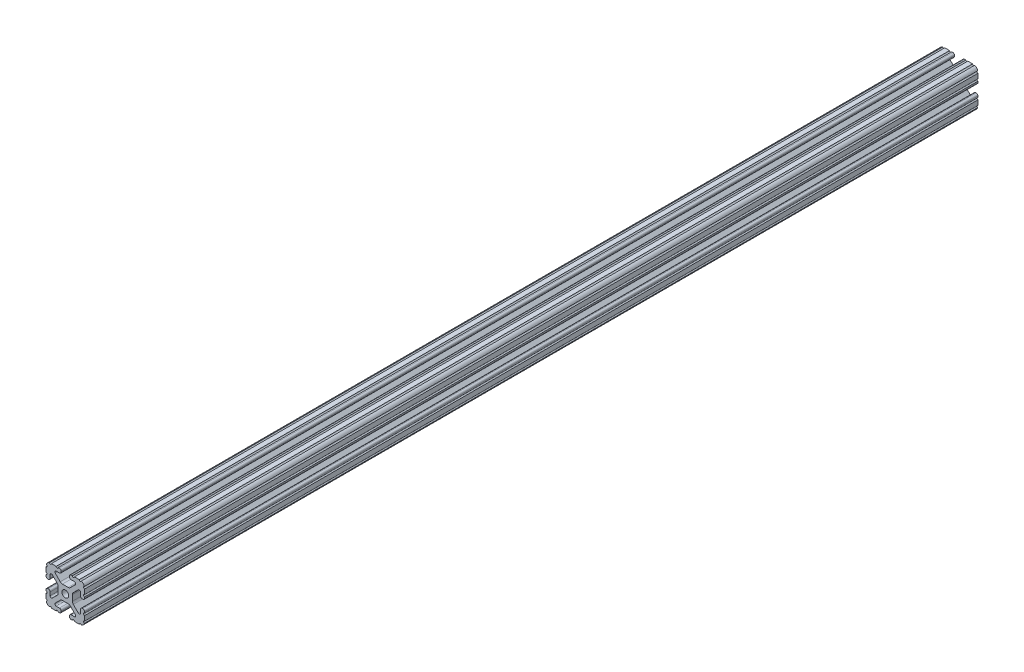
from build123d import *

# Parameters (mm, degrees)
BOSS_EXTRUDE1_DEPTH     = 440.817
SKETCH5_R               = 1.016
CUT_EXTRUDE1_DEPTH      = 441.817
CUT_EXTRUDE1_DEPTH_BACK = 441.817


with BuildPart() as part:
    # Sketch4 → Boss-Extrude1 (new body, symmetric)
    with BuildSketch(Plane.XY):
        with BuildLine():
            Line((5.7912, -19.05), (14.3002, -19.05))
            ThreePointArc((14.3002, -19.05), (17.658815789, -17.658815789), (19.05, -14.3002))
            Line((19.05, -14.3002), (19.05, -5.7912))
            ThreePointArc((19.05, -5.7912), (18.544114832, -4.569885168), (17.3228, -4.064))
            Line((17.3228, -4.064), (16.7132, -4.064))
            ThreePointArc((16.7132, -4.064), (15.491885168, -4.569885168), (14.986, -5.7912))
            Line((14.986, -5.7912), (14.986, -8.996305235))
            ThreePointArc((14.986, -8.996305235), (14.189232738, -10.188751711), (12.782646215, -9.908964256))
            Line((12.782646215, -9.908964256), (7.888897763, -5.015215804))
            ThreePointArc((7.888897763, -5.015215804), (7.219915375, -4.014012907), (6.985, -2.833013566))
            Line((6.985, -2.833013566), (6.985, 0))
            Line((6.985, 0), (3.3274, 0))
            ThreePointArc((3.3274, 0), (2.352827104, -2.352827104), (0, -3.3274))
            Line((0, -3.3274), (0, -6.985))
            Line((0, -6.985), (2.833013566, -6.985))
            ThreePointArc((2.833013566, -6.985), (4.014012907, -7.219915375), (5.015215804, -7.888897763))
            Line((5.015215804, -7.888897763), (9.908964256, -12.782646215))
            ThreePointArc((9.908964256, -12.782646215), (10.188751711, -14.189232738), (8.996305235, -14.986))
            Line((8.996305235, -14.986), (5.7912, -14.986))
            ThreePointArc((5.7912, -14.986), (4.569885168, -15.491885168), (4.064, -16.7132))
            Line((4.064, -16.7132), (4.064, -17.3228))
            ThreePointArc((4.064, -17.3228), (4.569885168, -18.544114832), (5.7912, -19.05))
        make_face()
    extrude(amount=BOSS_EXTRUDE1_DEPTH, both=True)

    # Sketch5 → Cut-Extrude1 (cut, two sides)
    with BuildSketch(Plane.XY) as cut_extrude1_sk:
        with Locations((14.739477062, -19.05)):
            Circle(SKETCH5_R)
        with Locations((7.980305235, -19.05)):
            Circle(SKETCH5_R)
        with Locations((19.05, -14.739477062)):
            Circle(SKETCH5_R)
        with Locations((19.05, -7.980305235)):
            Circle(SKETCH5_R)
    extrude(amount=CUT_EXTRUDE1_DEPTH, mode=Mode.SUBTRACT)
    extrude(cut_extrude1_sk.sketch, amount=-CUT_EXTRUDE1_DEPTH_BACK, mode=Mode.SUBTRACT)

    # Mirror1: part across plane


with BuildPart() as part_1:
    add(part.part)
    add(part.part.mirror(Plane(origin=(0, 0, 0), x_dir=(0, 0, 1), z_dir=(1, 0, 0))))

    # Mirror2: part across plane


with BuildPart() as part_2:
    add(part_1.part)
    add(part_1.part.mirror(Plane.ZX))


solid = part_2.part
